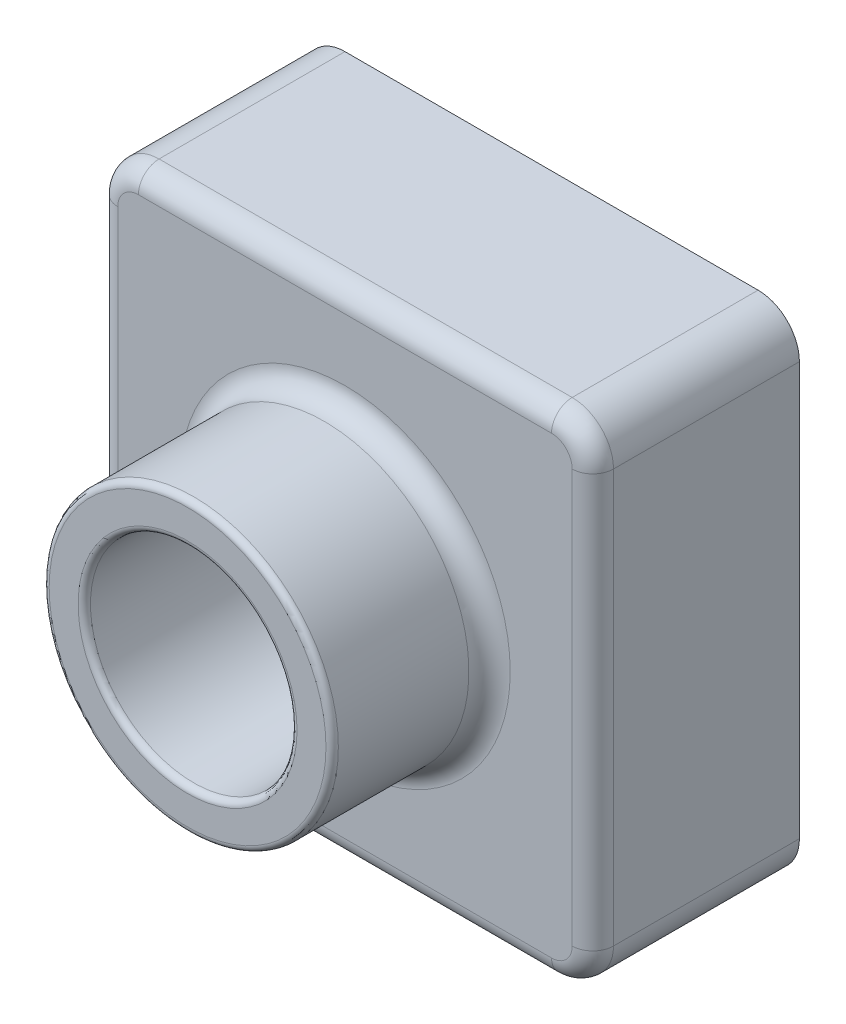
from build123d import *

# Parameters (mm, degrees)
SKETCH1_W           = 120
SKETCH1_H           = 120
BOSS_EXTRUDE1_DEPTH = 50
SKETCH2_R           = 35
BOSS_EXTRUDE2_DEPTH = 38.1
SKETCH6_R           = 25
BOSS_EXTRUDE6_DEPTH = 88.1
SKETCH7_R           = 25
BOSS_EXTRUDE7_DEPTH = 88.1
SKETCH8_R           = 25
CUT_EXTRUDE1_DEPTH  = 89.1
FILLET1_R           = 10
FILLET2_R           = 1.5
FILLET3_R           = 5
SHELL2_T            = -2


with BuildPart() as part:
    # Sketch1 → Boss-Extrude1 (new body)
    with BuildSketch(Plane.XY):
        with Locations((60, 60)):
            Rectangle(SKETCH1_W, SKETCH1_H)
    extrude(amount=BOSS_EXTRUDE1_DEPTH)

    # Sketch2 → Boss-Extrude2 (add)
    with BuildSketch(Plane.XY.offset(50)):
        with Locations((60, 60)):
            Circle(SKETCH2_R)
    extrude(amount=BOSS_EXTRUDE2_DEPTH)

    # Sketch6 → Boss-Extrude6 (add, through all)
    with BuildSketch(Plane.XY.offset(88.1)):
        with Locations((60, 60)):
            Circle(SKETCH6_R)
    extrude(amount=-BOSS_EXTRUDE6_DEPTH)

    # Sketch7 → Boss-Extrude7 (add, through all)
    with BuildSketch(Plane.XY.offset(88.1)):
        with Locations((60, 60)):
            Circle(SKETCH7_R)
    extrude(amount=-BOSS_EXTRUDE7_DEPTH)

    # Sketch8 → Cut-Extrude1 (cut, through all)
    with BuildSketch(Plane.XY.offset(88.1)):
        with Locations((60, 60)):
            Circle(SKETCH8_R)
    extrude(amount=-CUT_EXTRUDE1_DEPTH, mode=Mode.SUBTRACT)

    # Fillet1
    fillet1_edges = [part.edges().sort_by_distance(p)[0] for p in [
        (0, 120, 25),
        (120, 120, 25),
        (120, 0, 25),
        (0, 0, 25),
    ]]
    fillet(fillet1_edges, radius=FILLET1_R)

    # Fillet2
    fillet2_edges = [part.edges().sort_by_distance(p)[0] for p in [
        (25, 60, 88.1),
        (35, 60, 88.1),
    ]]
    fillet(fillet2_edges, radius=FILLET2_R)

    # Fillet3
    fillet3_edges = [part.edges().sort_by_distance(p)[0] for p in [
        (25, 60, 50),
        (60, 0, 50),
        (0, 60, 50),
        (120, 60, 50),
        (60, 120, 50),
        (117.071067812, 117.071067812, 50),
        (117.071067812, 2.928932188, 50),
        (2.928932188, 117.071067812, 50),
        (2.928932188, 2.928932188, 50),
    ]]
    fillet(fillet3_edges, radius=FILLET3_R)

    # Shell2
    shell2_openings = [part.faces().sort_by_distance(p)[0] for p in [
        (85, 60, 0),
    ]]
    offset(amount=SHELL2_T, openings=shell2_openings, kind=Kind.INTERSECTION)


solid = part.part
